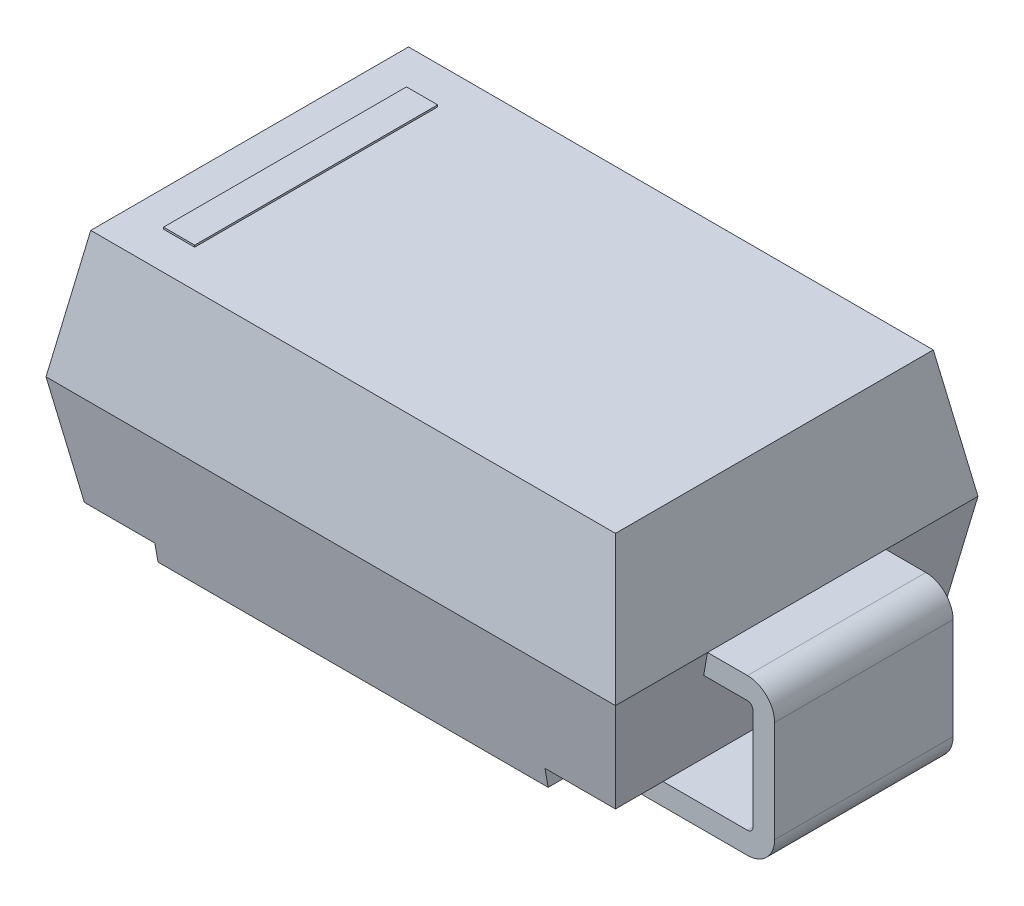
from build123d import *

# Parameters (mm, degrees)
SKETCH1_W                      = 3.99
SKETCH1_H                      = 2.54
BOSS_EXTRUDE1_DEPTH            = 0.888500052
BOSS_EXTRUDE1_TAPER            = 10
BOSS_EXTRUDE1_OTHER_WAY_DEPTH  = 0.888500052
BOSS_EXTRUDE1_OTHER_WAY_TAPER  = 10
BOSS_EXTRUDE2_DEPTH            = 0.625
CUT_EXTRUDE1_REACH             = 3.27
CUT_EXTRUDE1_DIRECTION_2_REACH = 3.27
SKETCH5_W                      = 0.218238159
SKETCH5_H                      = 1.702257636
BOSS_EXTRUDE3_DEPTH            = 0.0127


with BuildPart() as part:
    # Sketch1 → Boss-Extrude1 (new body)
    with BuildSketch(Plane(origin=(0, 0, 0), x_dir=(1, 0, 0), z_dir=(0, 1, 0))):
        Rectangle(SKETCH1_W, SKETCH1_H)
    extrude(amount=BOSS_EXTRUDE1_DEPTH, taper=BOSS_EXTRUDE1_TAPER)

    # Sketch1 → Boss-Extrude1 other way (add)
    with BuildSketch(Plane(origin=(0, 0, 0), x_dir=(1, 0, 0), z_dir=(0, 1, 0))):
        Rectangle(SKETCH1_W, SKETCH1_H)
    extrude(amount=-BOSS_EXTRUDE1_OTHER_WAY_DEPTH, taper=BOSS_EXTRUDE1_OTHER_WAY_TAPER)

    # Sketch2 → Boss-Extrude2 (add, symmetric)
    with BuildSketch(Plane.XY):
        with BuildLine():
            Line((-1.995, 0), (-2.2745, 0))
            ThreePointArc((-2.2745, 0), (-2.409203842, -0.055796158), (-2.465, -0.1905))
            Line((-2.465, -0.1905), (-2.465, -0.900999948))
            ThreePointArc((-2.465, -0.900999948), (-2.409203842, -1.03570379), (-2.2745, -1.091499948))
            Line((-2.2745, -1.091499948), (-1.4182914, -1.091499948))
            Line((-1.4182914, -1.091499948), (-1.4182914, -0.939099948))
            Line((-1.4182914, -0.939099948), (-2.2745, -0.939099948))
            ThreePointArc((-2.2745, -0.939099948), (-2.301440768, -0.927940716), (-2.3126, -0.900999948))
            Line((-2.3126, -0.900999948), (-2.3126, -0.1905))
            ThreePointArc((-2.3126, -0.1905), (-2.301440768, -0.163559232), (-2.2745, -0.1524))
            Line((-2.2745, -0.1524), (-1.968127768, -0.1524))
            Line((-1.968127768, -0.1524), (-1.995, 0))
        make_face()
        with BuildLine():
            Line((2.2745, -1.091499948), (1.4182914, -1.091499948))
            Line((1.4182914, -1.091499948), (1.4182914, -0.939099948))
            Line((1.4182914, -0.939099948), (2.2745, -0.939099948))
            ThreePointArc((2.2745, -0.939099948), (2.301440768, -0.927940716), (2.3126, -0.900999948))
            Line((2.3126, -0.900999948), (2.3126, -0.1905))
            ThreePointArc((2.3126, -0.1905), (2.301440768, -0.163559232), (2.2745, -0.1524))
            Line((2.2745, -0.1524), (1.968127768, -0.1524))
            Line((1.968127768, -0.1524), (1.995, 0))
            Line((1.995, 0), (2.2745, 0))
            ThreePointArc((2.2745, 0), (2.409203842, -0.055796158), (2.465, -0.1905))
            Line((2.465, -0.1905), (2.465, -0.900999948))
            ThreePointArc((2.465, -0.900999948), (2.409203842, -1.03570379), (2.2745, -1.091499948))
        make_face()
    extrude(amount=BOSS_EXTRUDE2_DEPTH, both=True)

    # Sketch3 → Cut-Extrude1 (cut, up to next)
    with BuildSketch(Plane.XY, mode=Mode.PRIVATE) as cut_extrude1_sk1:
        Polygon((-1.838333468, -0.888500052), (-1.366716467, -0.888500052), (-1.366716467, -0.761670377), (-1.860696962, -0.761670377), align=None)
    cut_extrude1_tool1 = extrude(cut_extrude1_sk1.sketch, amount=-CUT_EXTRUDE1_REACH, mode=Mode.PRIVATE) & part.part
    add(cut_extrude1_tool1.solids().sort_by_distance((-1.608159, -0.824596, 0))[0], mode=Mode.SUBTRACT)
    # Sketch3 → Cut-Extrude1 (cut, up to next)
    with BuildSketch(Plane.XY, mode=Mode.PRIVATE) as cut_extrude1_sk2:
        Polygon((1.838333468, -0.888500052), (1.860696962, -0.761670377), (1.366716467, -0.761670377), (1.366716467, -0.888500052), align=None)
    cut_extrude1_tool2 = extrude(cut_extrude1_sk2.sketch, amount=-CUT_EXTRUDE1_REACH, mode=Mode.PRIVATE) & part.part
    add(cut_extrude1_tool2.solids().sort_by_distance((1.608159, -0.824596, 0))[0], mode=Mode.SUBTRACT)

    # Sketch3 → Cut-Extrude1 direction 2 (cut, up to next)
    with BuildSketch(Plane.XY, mode=Mode.PRIVATE) as cut_extrude1_direction_2_sk1:
        Polygon((-1.838333468, -0.888500052), (-1.366716467, -0.888500052), (-1.366716467, -0.761670377), (-1.860696962, -0.761670377), align=None)
    cut_extrude1_direction_2_tool1 = extrude(cut_extrude1_direction_2_sk1.sketch, amount=CUT_EXTRUDE1_DIRECTION_2_REACH, mode=Mode.PRIVATE) & part.part
    add(cut_extrude1_direction_2_tool1.solids().sort_by_distance((-1.608159, -0.824596, 0))[0], mode=Mode.SUBTRACT)
    # Sketch3 → Cut-Extrude1 direction 2 (cut, up to next)
    with BuildSketch(Plane.XY, mode=Mode.PRIVATE) as cut_extrude1_direction_2_sk2:
        Polygon((1.838333468, -0.888500052), (1.860696962, -0.761670377), (1.366716467, -0.761670377), (1.366716467, -0.888500052), align=None)
    cut_extrude1_direction_2_tool2 = extrude(cut_extrude1_direction_2_sk2.sketch, amount=CUT_EXTRUDE1_DIRECTION_2_REACH, mode=Mode.PRIVATE) & part.part
    add(cut_extrude1_direction_2_tool2.solids().sort_by_distance((1.608159, -0.824596, 0))[0], mode=Mode.SUBTRACT)

    # Sketch5 → Boss-Extrude3 (add)
    with BuildSketch(Plane(origin=(0, 0.888500052, 0), x_dir=(1, 0, 0), z_dir=(0, 1, 0))):
        with Locations((-1.481291501, 0)):
            Rectangle(SKETCH5_W, SKETCH5_H)
    extrude(amount=BOSS_EXTRUDE3_DEPTH)


solid = part.part
